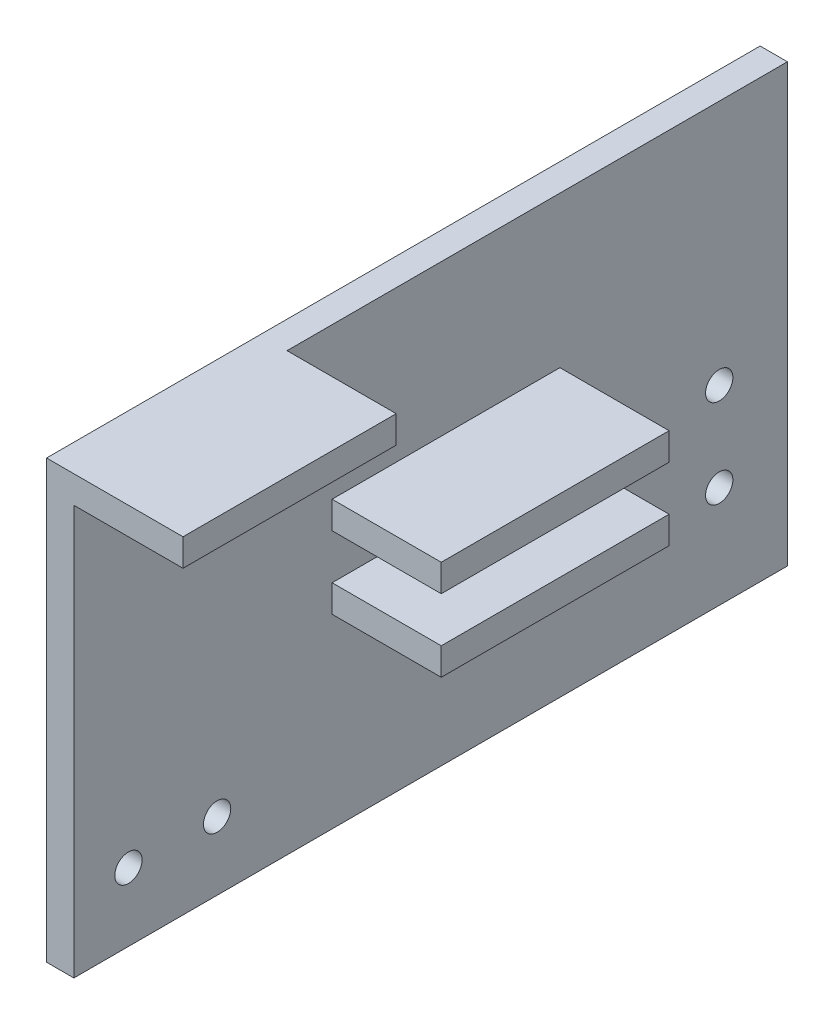
from build123d import *

# Parameters (mm, degrees)
SKETCH1_W           = 52.3
SKETCH1_H           = 32.007
SKETCH1_R           = 1
BOSS_EXTRUDE1_DEPTH = 2
SKETCH1_3_W         = 15.625
SKETCH1_3_H         = 2
SKETCH1_3_W_2       = 16.698
BOSS_EXTRUDE2_DEPTH = 10


with BuildPart() as part:
    # Sketch1 → Boss-Extrude1 (new body)
    with BuildSketch(Plane(origin=(0, 0, 0), x_dir=(0, 0, -1), z_dir=(1, 0, 0))):
        with Locations((26.15, -1.27147436)):
            Rectangle(SKETCH1_W, SKETCH1_H)
        with Locations((4, -12.27497436)):
            Circle(SKETCH1_R, mode=Mode.SUBTRACT)
        with Locations((10.5, -12.27497436)):
            Circle(SKETCH1_R, mode=Mode.SUBTRACT)
        with Locations((47.3, -9.8)):
            Circle(SKETCH1_R, mode=Mode.SUBTRACT)
        with Locations((47.3, -3.3)):
            Circle(SKETCH1_R, mode=Mode.SUBTRACT)
    extrude(amount=BOSS_EXTRUDE1_DEPTH)

    # Sketch1_3 → Boss-Extrude2 (add)
    with BuildSketch(Plane(origin=(0, 0, 0), x_dir=(0, 0, -1), z_dir=(1, 0, 0))):
        with Locations((7.8125, 13.73202564)):
            Rectangle(SKETCH1_3_W, SKETCH1_3_H)
        with Locations((27.276, 2.651)):
            Rectangle(SKETCH1_3_W_2, SKETCH1_3_H)
        with Locations((27.276, -2.651)):
            Rectangle(SKETCH1_3_W_2, SKETCH1_3_H)
    extrude(amount=BOSS_EXTRUDE2_DEPTH)


solid = part.part
